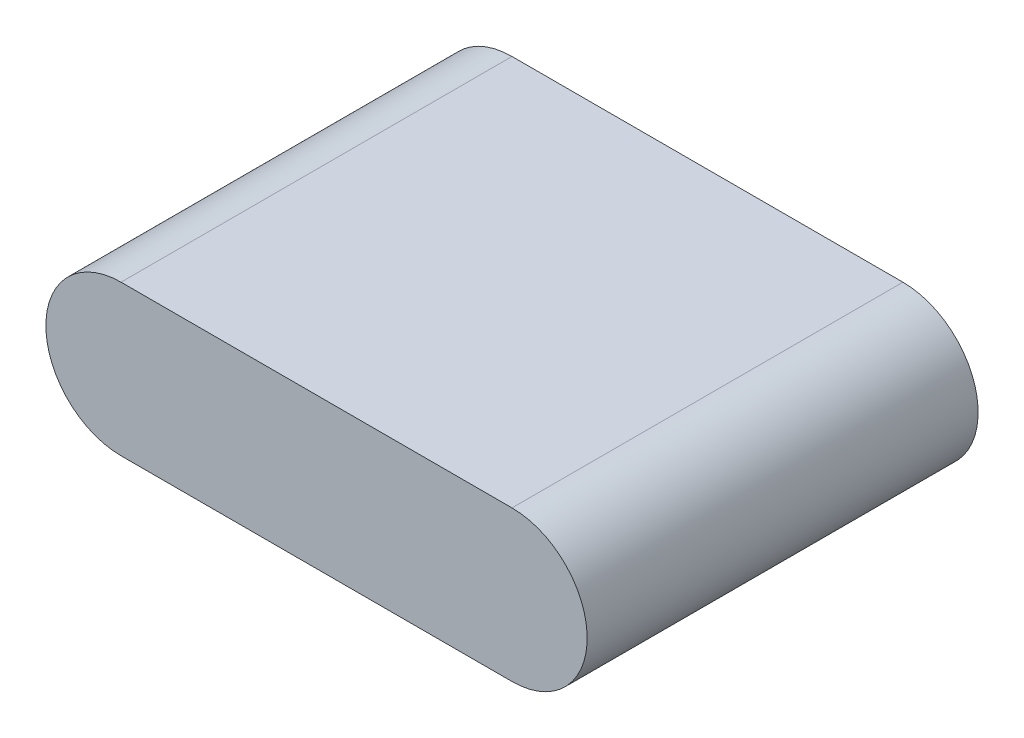
from build123d import *

# Parameters (mm, degrees)
BOSS_EXTRU_1_DEPTH = 78


with BuildPart() as part:
    # Esquisse1 → Boss.-Extru.1 (new body)
    with BuildSketch(Plane.XY):
        with BuildLine():
            Line((0, 15), (78, 15))
            ThreePointArc((78, 15), (93, 0), (78, -15))
            Line((78, -15), (0, -15))
            ThreePointArc((0, -15), (-15, 0), (0, 15))
        make_face()
    extrude(amount=BOSS_EXTRU_1_DEPTH)


solid = part.part
